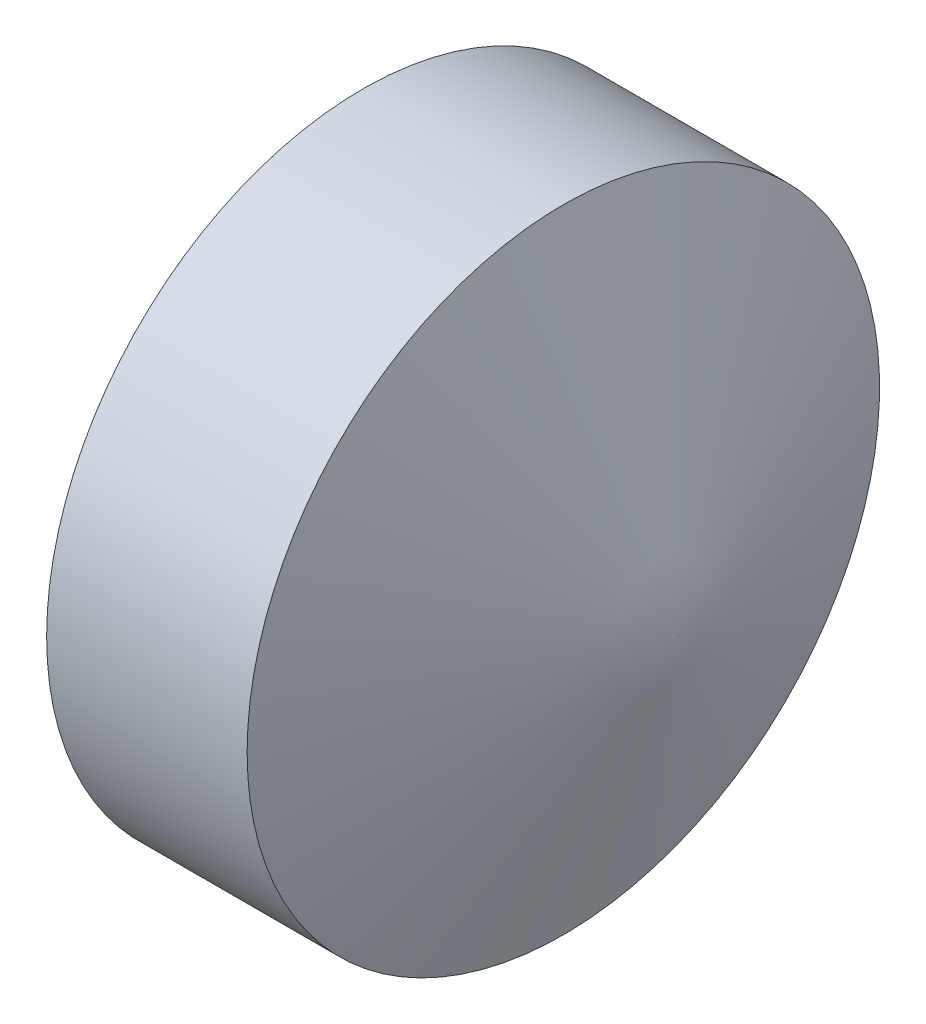
from build123d import *

# Parameters (mm, degrees)
CORTE_EXTRUS_O1_DEPTH = 1.2
CHANFRO1_SIZE         = 0.2535
CHANFRO1_SIZE2        = 0.146358293


with BuildPart() as part:
    # Esboço1 → Revolução1 (revolve)
    with BuildSketch(Plane(origin=(0, 0, 0), x_dir=(-1, 0, 0), z_dir=(0, 0, -1))):
        Polygon((-2.506336445, 1.356329469), (-3, 0), (-1.5, 0), (-1.5, 1.356329469), align=None)
    revolve(axis=Axis((3, 0, 0), (-1, 0, 0)))

    # Esboço2 → Corte-extrusão1 (cut)
    with BuildSketch(Plane.ZY.offset(-1.5)):
        Polygon((0.375277675, -0.65), (0.75055535, 0), (0.375277675, 0.65), (-0.375277675, 0.65), (-0.75055535, 0), (-0.375277675, -0.65), align=None)
    extrude(amount=-CORTE_EXTRUS_O1_DEPTH, mode=Mode.SUBTRACT)

    # Chanfro1
    chanfro1_edges = [part.edges().sort_by_distance(p)[0] for p in [
        (1.5, -1.356329469, 0),
    ]]
    chanfro1_side = [part.faces().sort_by_distance(p)[0] for p in [
        (1.5, -1.317966678, 0),
    ]]
    chamfer(chanfro1_edges, length=CHANFRO1_SIZE, length2=CHANFRO1_SIZE2, reference=chanfro1_side[0])


solid = part.part
